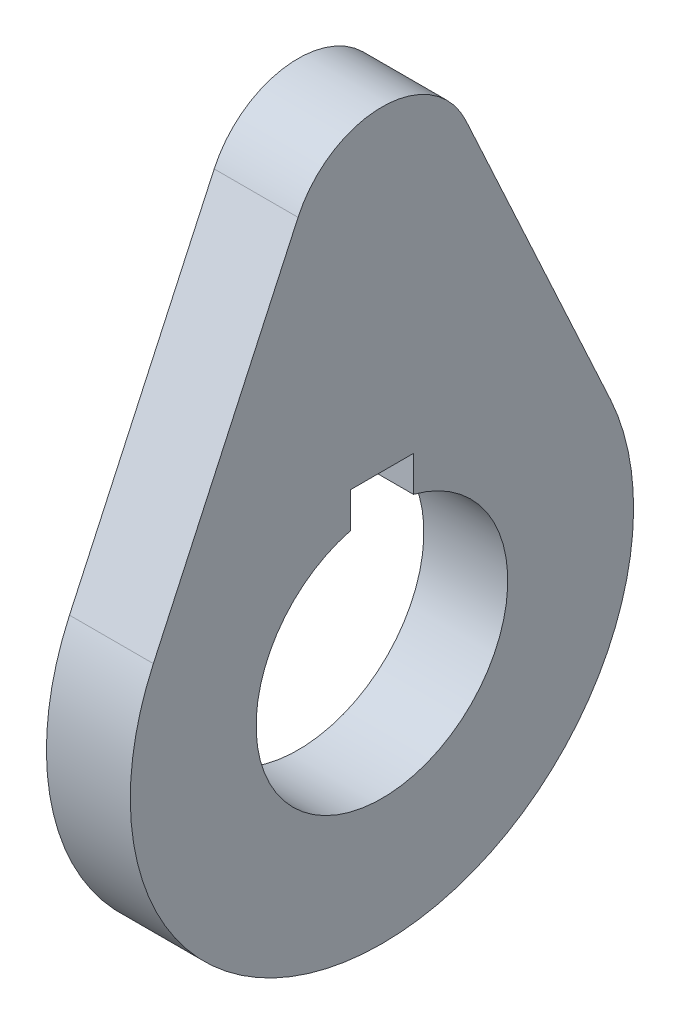
from build123d import *

# Parameters (mm, degrees)
SKETCH1_R           = 38.1
SKETCH1_R_2         = 19.05
BOSS_EXTRUDE1_DEPTH = 12.7
SKETCH2_W           = 9.525
SKETCH2_H           = 9.525
CUT_EXTRUDE1_DEPTH  = 13.7
BOSS_EXTRUDE2_DEPTH = 12.7


with BuildPart() as part:
    # Sketch1 → Boss-Extrude1 (new body)
    with BuildSketch(Plane(origin=(0, 0, 0), x_dir=(0, 0, -1), z_dir=(1, 0, 0))):
        Circle(SKETCH1_R)
        Circle(SKETCH1_R_2, mode=Mode.SUBTRACT)
    extrude(amount=BOSS_EXTRUDE1_DEPTH)

    # Sketch2 → Cut-Extrude1 (cut, through all)
    with BuildSketch(Plane(origin=(12.7, 0, 0), x_dir=(0, 0, -1), z_dir=(1, 0, 0))):
        with Locations((0, 19.05)):
            Rectangle(SKETCH2_W, SKETCH2_H)
    extrude(amount=-CUT_EXTRUDE1_DEPTH, mode=Mode.SUBTRACT)

    # Sketch3 → Boss-Extrude2 (add)
    with BuildSketch(Plane(origin=(12.7, 0, 0), x_dir=(0, 0, -1), z_dir=(1, 0, 0))):
        with BuildLine():
            Line((-34.605831603, 15.938833679), (-12.7, 63.5))
            ThreePointArc((-12.7, 63.5), (0, 71.632930181), (12.7, 63.5))
            Line((12.7, 63.5), (34.605831603, 15.938833679))
            ThreePointArc((34.605831603, 15.938833679), (0, 38.1), (-34.605831603, 15.938833679))
        make_face()
    extrude(amount=-BOSS_EXTRUDE2_DEPTH)


solid = part.part
